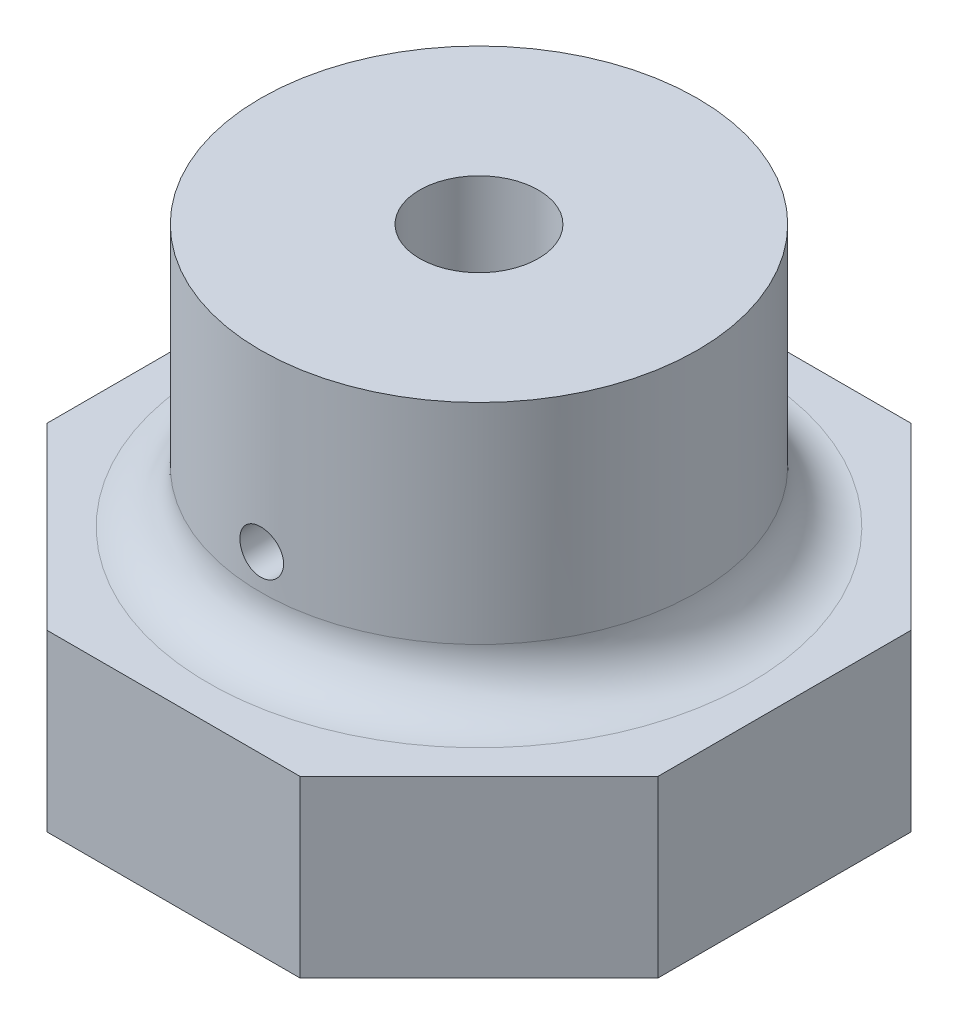
from build123d import *

# Parameters (mm, degrees)
SKETCH2_R               = 12.5
BOSS_EXTRUDE2_DEPTH     = 25
SKETCH3_R               = 3.4
CUT_EXTRUDE1_DEPTH      = 30
SKETCH4_R               = 1.25
CUT_EXTRUDE2_DEPTH      = 13.5
CUT_EXTRUDE2_DEPTH_BACK = 2.5
BOSS_EXTRUDE3_DEPTH     = 10
FILLET2_R               = 3


with BuildPart() as part:
    # Sketch2 → Boss-Extrude2 (new body)
    with BuildSketch(Plane(origin=(0, 0, 0), x_dir=(1, 0, 0), z_dir=(0, 1, 0))):
        Circle(SKETCH2_R)
    extrude(amount=BOSS_EXTRUDE2_DEPTH)

    # Sketch3 → Cut-Extrude1 (cut)
    with BuildSketch(Plane(origin=(0, 25, 0), x_dir=(1, 0, 0), z_dir=(0, 1, 0))):
        Circle(SKETCH3_R)
    extrude(amount=-CUT_EXTRUDE1_DEPTH, mode=Mode.SUBTRACT)

    # Sketch4 → Cut-Extrude2 (cut, two sides)
    with BuildSketch(Plane.XY) as cut_extrude2_sk:
        with Locations((0, 15)):
            Circle(SKETCH4_R)
    extrude(amount=CUT_EXTRUDE2_DEPTH, mode=Mode.SUBTRACT)
    extrude(cut_extrude2_sk.sketch, amount=-CUT_EXTRUDE2_DEPTH_BACK, mode=Mode.SUBTRACT)

    # Sketch5 → Boss-Extrude3 (add)
    with BuildSketch(Plane.XZ):
        Polygon((7.248737342, -17.5), (17.5, -7.248737342), (17.5, 7.248737342), (7.248737342, 17.5), (-7.248737342, 17.5), (-17.5, 7.248737342), (-17.5, -7.248737342), (-7.248737342, -17.5), align=None)
    extrude(amount=-BOSS_EXTRUDE3_DEPTH)

    # Fillet2
    fillet2_edges = [part.edges().sort_by_distance(p)[0] for p in [
        (-12.5, 10, 0),
    ]]
    fillet(fillet2_edges, radius=FILLET2_R)


solid = part.part
